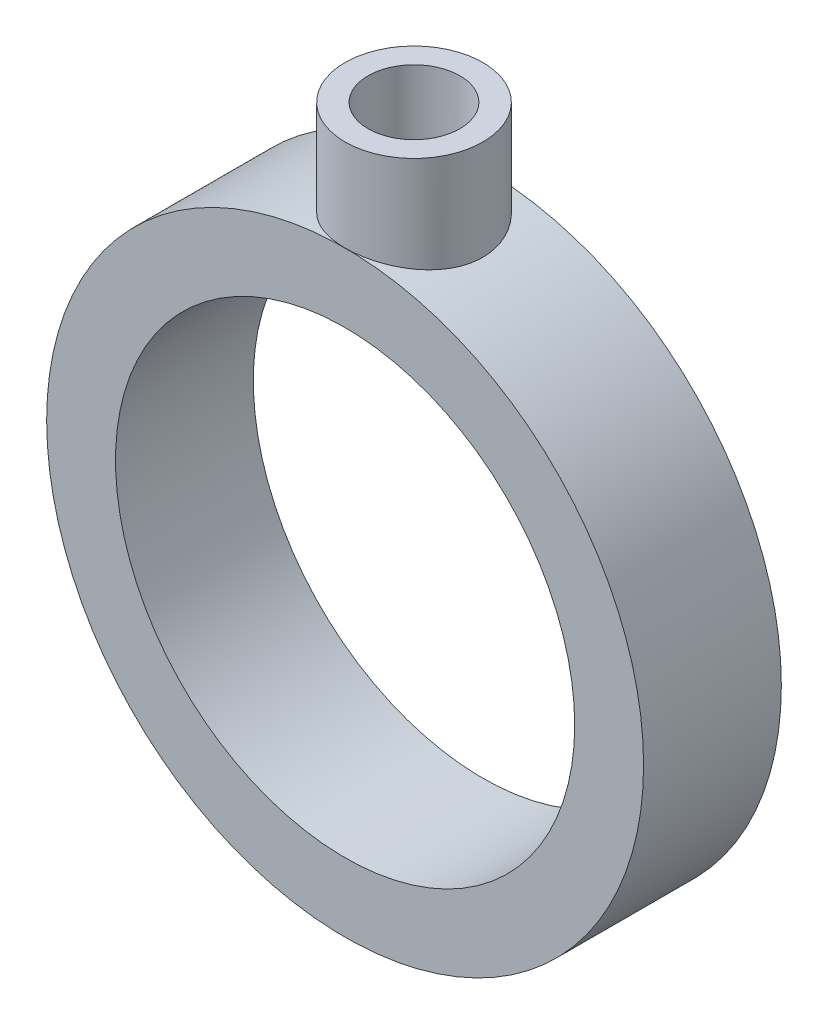
from build123d import *

# Parameters (mm, degrees)
SKETCH1_R                = 13
SKETCH1_R_2              = 10
BOSS_EXTRUDE1_DEPTH      = 3
BOSS_EXTRUDE2_REACH      = 37.628
BOSS_EXTRUDE2_END_RADIUS = 13
BOSS_EXTRUDE2_START      = 17
SKETCH2_R                = 3
SKETCH3_R                = 2
CUT_EXTRUDE1_DEPTH       = 10


with BuildPart() as part:
    # Sketch1 → Boss-Extrude1 (new, symmetric)
    with BuildSketch(Plane.XY):
        Circle(SKETCH1_R)
        Circle(SKETCH1_R_2, mode=Mode.SUBTRACT)
    extrude(amount=BOSS_EXTRUDE1_DEPTH, both=True)


with BuildPart() as body_2:
    # Boss-Extrude2: up to this cylinder (the profile starts outside it)
    boss_extrude2_end = Plane(origin=(0, 0, 0), z_dir=(0, 0, -1)) * Cylinder(BOSS_EXTRUDE2_END_RADIUS, 102.256, mode=Mode.PRIVATE)
    # Sketch2 → Boss-Extrude2 (new, up to the surface)
    with BuildSketch(Plane(origin=(0, 0, 0), x_dir=(1, 0, 0), z_dir=(0, 1, 0)).offset(BOSS_EXTRUDE2_START), mode=Mode.PRIVATE) as boss_extrude2_sk1:
        with Locations(Location((0, 0, 0), (0, 0, 270))):
            Circle(SKETCH2_R)
    boss_extrude2_tool1 = extrude(boss_extrude2_sk1.sketch, amount=-BOSS_EXTRUDE2_REACH, mode=Mode.PRIVATE) - boss_extrude2_end
    add(boss_extrude2_tool1.solids().sort_by_distance((0, 17, 0))[0])


with BuildPart() as cut_extrude1_tool:
    # Sketch3 → Cut-Extrude1 (new body)
    with BuildSketch(Plane(origin=(0, 17, 0), x_dir=(1, 0, 0), z_dir=(0, 1, 0))):
        with Locations(Location((0, 0, 0), (0, 0, 270))):
            Circle(SKETCH3_R)
    extrude(amount=-CUT_EXTRUDE1_DEPTH)


with BuildPart() as part_1:
    add(part.part)

    # Cut-Extrude1: cut by cut_extrude1_tool
    add(cut_extrude1_tool.part, mode=Mode.SUBTRACT)


with BuildPart() as body_2_1:
    add(body_2.part)

    # Cut-Extrude1: cut by cut_extrude1_tool
    add(cut_extrude1_tool.part, mode=Mode.SUBTRACT)


solid = Compound([part_1.part, body_2_1.part])
